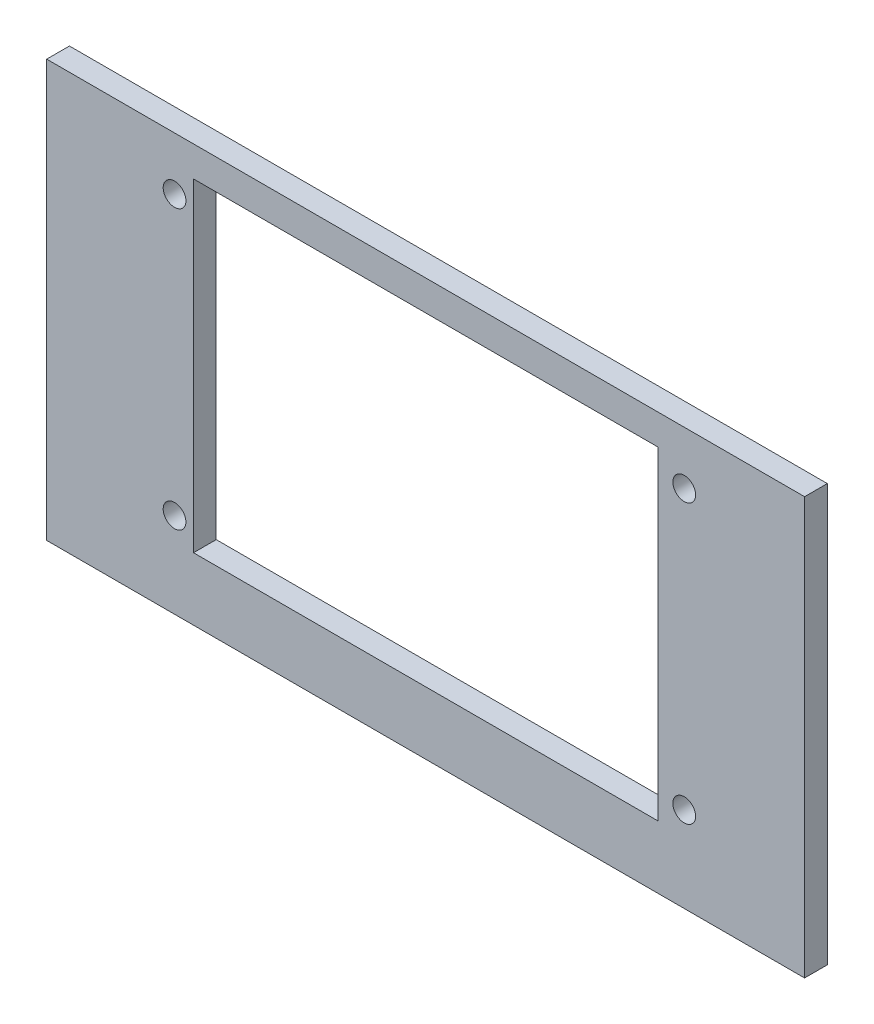
from build123d import *

# Parameters (mm, degrees)
SKETCH1_W           = 100
SKETCH1_H           = 55
SKETCH1_R           = 1.5
SKETCH1_W_2         = 61.26
SKETCH1_H_2         = 42.72
BOSS_EXTRUDE1_DEPTH = 3


with BuildPart() as part:
    # Sketch1 → Boss-Extrude1 (new body)
    with BuildSketch(Plane.XY):
        with Locations((50, 27.5)):
            Rectangle(SKETCH1_W, SKETCH1_H)
        with Locations((84.12, 48)):
            Circle(SKETCH1_R, mode=Mode.SUBTRACT)
        with Locations((16.87, 48)):
            Circle(SKETCH1_R, mode=Mode.SUBTRACT)
        with Locations((16.87, 11.28)):
            Circle(SKETCH1_R, mode=Mode.SUBTRACT)
        with Locations((84.12, 11.28)):
            Circle(SKETCH1_R, mode=Mode.SUBTRACT)
        with Locations((50, 29.64)):
            Rectangle(SKETCH1_W_2, SKETCH1_H_2, mode=Mode.SUBTRACT)
    extrude(amount=BOSS_EXTRUDE1_DEPTH)


solid = part.part
